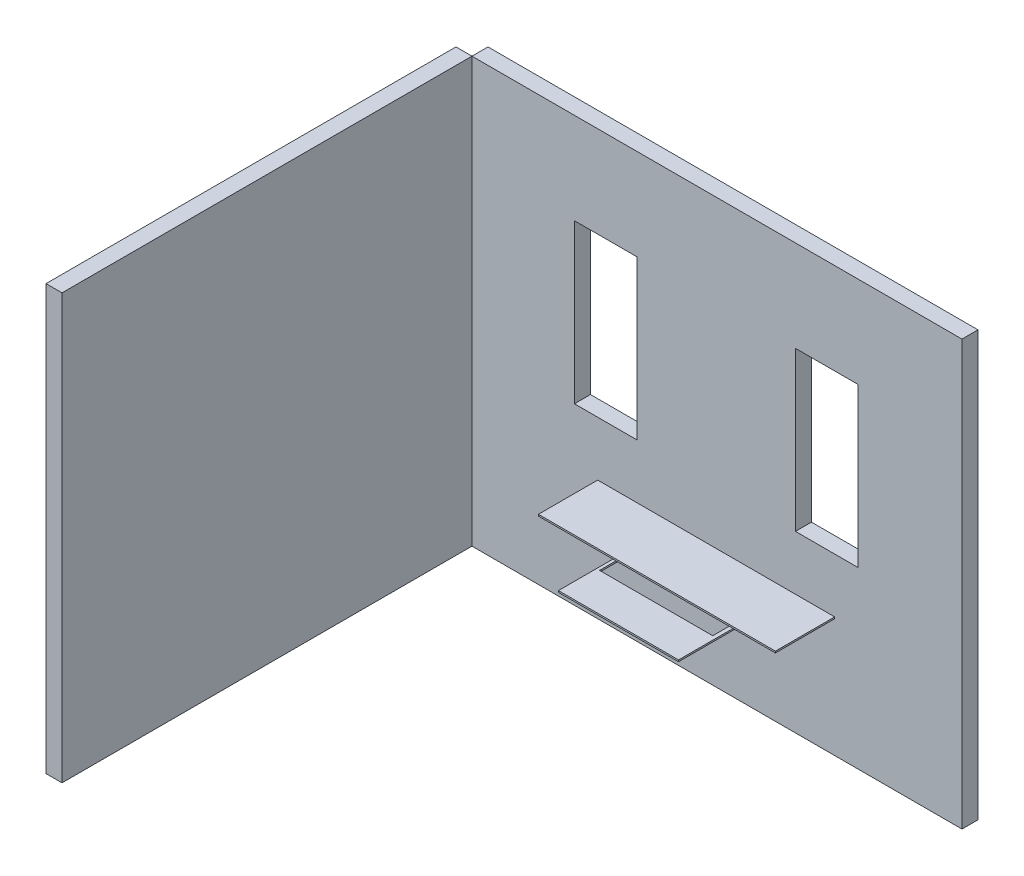
from build123d import *

# Parameters (mm, degrees)
ESBO_O6_W                = 3060
ESBO_O6_H                = 2650
RESSALTO_EXTRUS_O2_DEPTH = 100
ESBO_O7_W                = 390
ESBO_O7_H                = 990
CORTE_EXTRUS_O1_DEPTH    = 749
ESBO_O8_W                = 100
ESBO_O8_H                = 2650
RESSALTO_EXTRUS_O3_DEPTH = 2560
ESBO_O14_W               = 1480
ESBO_O14_H               = 10
RESSALTO_EXTRUS_O6_DEPTH = 370
ESBO_O16_W               = 750
ESBO_O16_H               = 10
RESSALTO_EXTRUS_O7_DEPTH = 710
ESBO_O17_W               = 707.085719873
ESBO_O17_H               = 372.624570159
CORTE_EXTRUS_O3_DEPTH    = 70


with BuildPart() as part:
    # Esboço6 → Ressalto-extrusão2 (new body)
    with BuildSketch(Plane.XY):
        with Locations((1530, 1325)):
            Rectangle(ESBO_O6_W, ESBO_O6_H)
    extrude(amount=RESSALTO_EXTRUS_O2_DEPTH)

    # Esboço7 → Corte-extrusão1 (cut)
    with BuildSketch(Plane.XY.offset(100)):
        with Locations((2215, 1585)):
            Rectangle(ESBO_O7_W, ESBO_O7_H)
        with Locations((835, 1585)):
            Rectangle(ESBO_O7_W, ESBO_O7_H)
    extrude(amount=-CORTE_EXTRUS_O1_DEPTH, mode=Mode.SUBTRACT)

    # Esboço14 → Ressalto-extrusão6 (add)
    with BuildSketch(Plane.XY.offset(100)):
        with Locations((1525, 745)):
            Rectangle(ESBO_O14_W, ESBO_O14_H)
    extrude(amount=RESSALTO_EXTRUS_O6_DEPTH)

    # Esboço16 → Ressalto-extrusão7 (add)
    with BuildSketch(Plane.XY):
        with Locations((1525, 635)):
            Rectangle(ESBO_O16_W, ESBO_O16_H)
    extrude(amount=RESSALTO_EXTRUS_O7_DEPTH)

    # Esboço17 → Corte-extrusão3 (cut)
    with BuildSketch(Plane.XZ.offset(-630)):
        with Locations((1522.610842488, 286.31228508)):
            Rectangle(ESBO_O17_W, ESBO_O17_H)
    extrude(amount=-CORTE_EXTRUS_O3_DEPTH, mode=Mode.SUBTRACT)


with BuildPart() as body_2:
    # Esboço8 → Ressalto-extrusão3 (new body)
    with BuildSketch(Plane.XY.offset(100)):
        with Locations((-50, 1325)):
            Rectangle(ESBO_O8_W, ESBO_O8_H)
    extrude(amount=RESSALTO_EXTRUS_O3_DEPTH)


solid = Compound([part.part, body_2.part])
